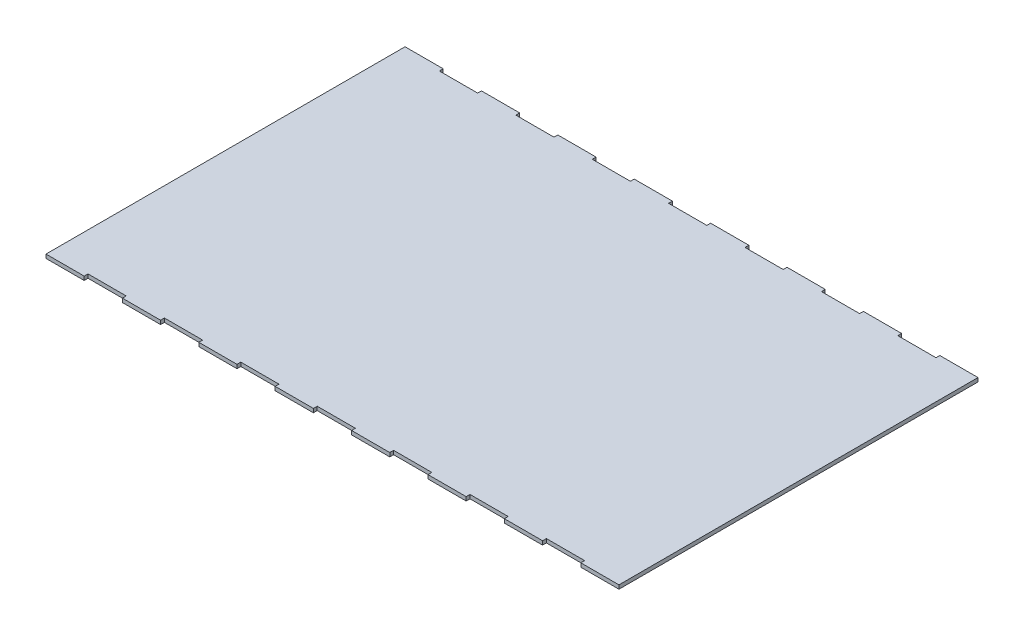
from build123d import *

# Parameters (mm, degrees)
SKETCH1_W               = 300
SKETCH1_H               = 188
BOSS_EXTRUDE1_DEPTH     = 2
SKETCH2_W               = 20
SKETCH2_H               = 2
CUT_EXTRUDE1_DEPTH      = 4
LPATTERN1_COUNT         = 8
LPATTERN1_PITCH         = 40
MIRROR1_COPY_1_SKETCH_W = 20
MIRROR1_COPY_1_SKETCH_H = 2
MIRROR1_COPY_1_DEPTH    = 4
MIRROR1_COPY_2_SKETCH_W = 20
MIRROR1_COPY_2_SKETCH_H = 2
MIRROR1_COPY_2_DEPTH    = 4
MIRROR1_COPY_3_SKETCH_W = 20
MIRROR1_COPY_3_SKETCH_H = 2
MIRROR1_COPY_3_DEPTH    = 4
MIRROR1_COPY_4_SKETCH_W = 20
MIRROR1_COPY_4_SKETCH_H = 2
MIRROR1_COPY_4_DEPTH    = 4
MIRROR1_COPY_5_SKETCH_W = 20
MIRROR1_COPY_5_SKETCH_H = 2
MIRROR1_COPY_5_DEPTH    = 4
MIRROR1_COPY_6_SKETCH_W = 20
MIRROR1_COPY_6_SKETCH_H = 2
MIRROR1_COPY_6_DEPTH    = 4
MIRROR1_COPY_7_SKETCH_W = 20
MIRROR1_COPY_7_SKETCH_H = 2
MIRROR1_COPY_7_DEPTH    = 4


with BuildPart() as part:
    # Sketch1 → Boss-Extrude1 (new body)
    with BuildSketch(Plane(origin=(0, 0, 0), x_dir=(1, 0, 0), z_dir=(0, 1, 0))):
        with Locations((-74.28137931, -28.264827586)):
            Rectangle(SKETCH1_W, SKETCH1_H)
    extrude(amount=BOSS_EXTRUDE1_DEPTH)

    # Sketch2 → Cut-Extrude1 (cut)
    with BuildSketch(Plane(origin=(0, 2, 0), x_dir=(1, 0, 0), z_dir=(0, 1, 0))):
        with Locations((-194.28137931, -121.264827586)):
            Rectangle(SKETCH2_W, SKETCH2_H)
    cut_extrude1 = extrude(amount=-CUT_EXTRUDE1_DEPTH, mode=Mode.SUBTRACT)

    # LPattern1: Cut-Extrude1 ×8
    with Locations(*[(i * LPATTERN1_PITCH, 0, 0) for i in range(1, LPATTERN1_COUNT)]):
        add(cut_extrude1, mode=Mode.SUBTRACT)

    # Mirror1: Cut-Extrude1 across plane
    add(cut_extrude1.mirror(Plane.XY.offset(28.264827586)), mode=Mode.SUBTRACT)

    # Mirror1 copy 1 sketch → Mirror1 copy 1 (cut)
    with BuildSketch(Plane(origin=(40, 2, 56.529655172), x_dir=(1, 0, 0), z_dir=(0, 1, 0))):
        with Locations((-194.28137931, 121.264827586)):
            Rectangle(MIRROR1_COPY_1_SKETCH_W, MIRROR1_COPY_1_SKETCH_H)
    extrude(amount=-MIRROR1_COPY_1_DEPTH, mode=Mode.SUBTRACT)

    # Mirror1 copy 2 sketch → Mirror1 copy 2 (cut)
    with BuildSketch(Plane(origin=(80, 2, 56.529655172), x_dir=(1, 0, 0), z_dir=(0, 1, 0))):
        with Locations((-194.28137931, 121.264827586)):
            Rectangle(MIRROR1_COPY_2_SKETCH_W, MIRROR1_COPY_2_SKETCH_H)
    extrude(amount=-MIRROR1_COPY_2_DEPTH, mode=Mode.SUBTRACT)

    # Mirror1 copy 3 sketch → Mirror1 copy 3 (cut)
    with BuildSketch(Plane(origin=(120, 2, 56.529655172), x_dir=(1, 0, 0), z_dir=(0, 1, 0))):
        with Locations((-194.28137931, 121.264827586)):
            Rectangle(MIRROR1_COPY_3_SKETCH_W, MIRROR1_COPY_3_SKETCH_H)
    extrude(amount=-MIRROR1_COPY_3_DEPTH, mode=Mode.SUBTRACT)

    # Mirror1 copy 4 sketch → Mirror1 copy 4 (cut)
    with BuildSketch(Plane(origin=(160, 2, 56.529655172), x_dir=(1, 0, 0), z_dir=(0, 1, 0))):
        with Locations((-194.28137931, 121.264827586)):
            Rectangle(MIRROR1_COPY_4_SKETCH_W, MIRROR1_COPY_4_SKETCH_H)
    extrude(amount=-MIRROR1_COPY_4_DEPTH, mode=Mode.SUBTRACT)

    # Mirror1 copy 5 sketch → Mirror1 copy 5 (cut)
    with BuildSketch(Plane(origin=(200, 2, 56.529655172), x_dir=(1, 0, 0), z_dir=(0, 1, 0))):
        with Locations((-194.28137931, 121.264827586)):
            Rectangle(MIRROR1_COPY_5_SKETCH_W, MIRROR1_COPY_5_SKETCH_H)
    extrude(amount=-MIRROR1_COPY_5_DEPTH, mode=Mode.SUBTRACT)

    # Mirror1 copy 6 sketch → Mirror1 copy 6 (cut)
    with BuildSketch(Plane(origin=(240, 2, 56.529655172), x_dir=(1, 0, 0), z_dir=(0, 1, 0))):
        with Locations((-194.28137931, 121.264827586)):
            Rectangle(MIRROR1_COPY_6_SKETCH_W, MIRROR1_COPY_6_SKETCH_H)
    extrude(amount=-MIRROR1_COPY_6_DEPTH, mode=Mode.SUBTRACT)

    # Mirror1 copy 7 sketch → Mirror1 copy 7 (cut)
    with BuildSketch(Plane(origin=(280, 2, 56.529655172), x_dir=(1, 0, 0), z_dir=(0, 1, 0))):
        with Locations((-194.28137931, 121.264827586)):
            Rectangle(MIRROR1_COPY_7_SKETCH_W, MIRROR1_COPY_7_SKETCH_H)
    extrude(amount=-MIRROR1_COPY_7_DEPTH, mode=Mode.SUBTRACT)


solid = part.part
